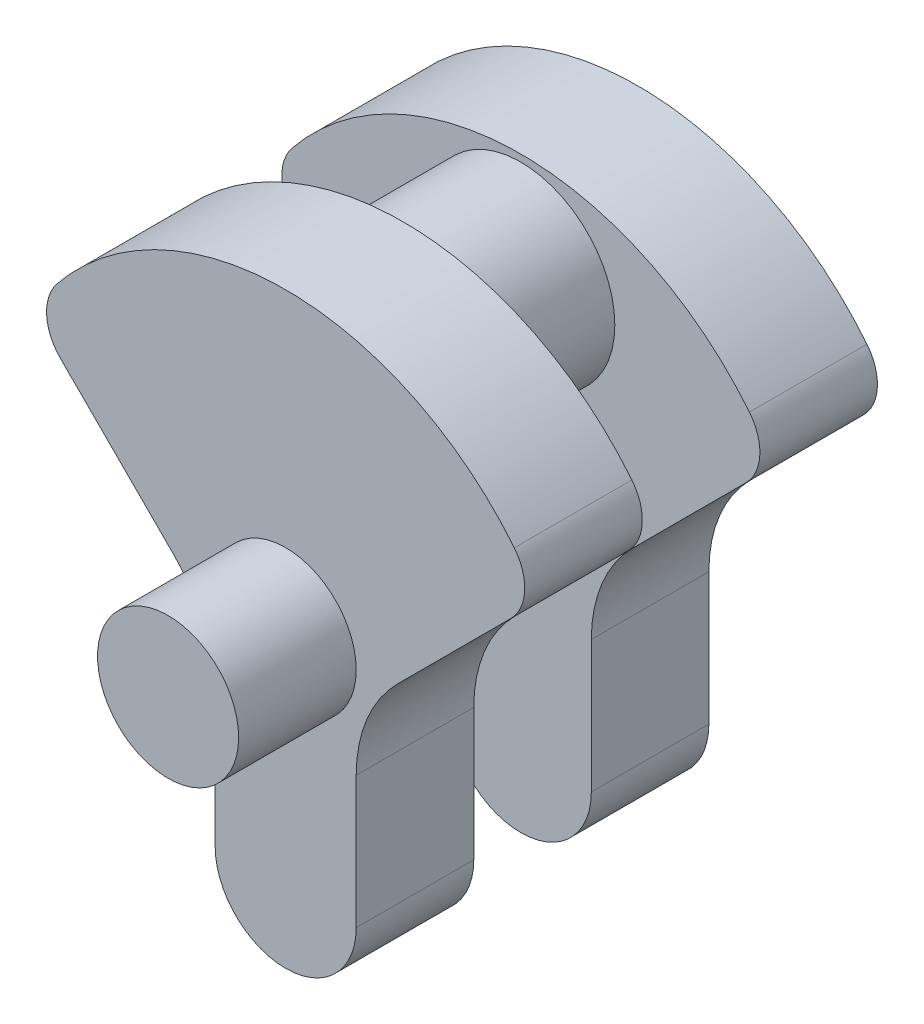
from build123d import *

# Parameters (mm, degrees)
BOSS_EXTRUDE1_DEPTH = 37.5
FILLET1_R           = 10
SKETCH4_W           = 25
SKETCH4_H           = 105.707635496
FILLET2_R           = 30
SKETCH5_R           = 15
BOSS_EXTRUDE2_DEPTH = 25


with BuildPart() as part:
    # Sketch2 → Boss-Extrude1 (new body, symmetric)
    with BuildSketch(Plane.XY):
        with BuildLine():
            Line((15, -47.5), (15, -7))
            Line((15, -7), (53.80332931, 31.80332931))
            ThreePointArc((53.80332931, 31.80332931), (0, 62.5), (-53.80332931, 31.80332931))
            Line((-53.80332931, 31.80332931), (-15, -7))
            Line((-15, -7), (-15, -47.5))
            ThreePointArc((-15, -47.5), (0, -62.5), (15, -47.5))
        make_face()
    extrude(amount=BOSS_EXTRUDE1_DEPTH, both=True)

    # Fillet1
    fillet1_edges = [part.edges().sort_by_distance(p)[0] for p in [
        (-53.80332931, 31.80332931, 0),
        (53.80332931, 31.80332931, 0),
    ]]
    fillet(fillet1_edges, radius=FILLET1_R)

    # Sketch4 → Cut-Revolve1 (revolve, cut)
    with BuildSketch(Plane(origin=(0, 0, 0), x_dir=(0, 0, -1), z_dir=(1, 0, 0)), mode=Mode.PRIVATE) as cut_revolve1_sk:
        with Locations((0, -31.853817748)):
            Rectangle(SKETCH4_W, SKETCH4_H)
    revolve(cut_revolve1_sk.sketch.rotate(Axis((0, 41, 37.5), (0, 0, -1)), 270), axis=Axis((0, 41, 37.5), (0, 0, -1)), mode=Mode.SUBTRACT)  # turned: the seam where the file's is

    # Fillet2
    fillet2_edges = [part.edges().sort_by_distance(p)[0] for p in [
        (15, -7, 25),
        (-15, -7, 25),
        (15, -7, -25),
        (-15, -7, -25),
    ]]
    fillet(fillet2_edges, radius=FILLET2_R)

    # Sketch5 → Boss-Extrude2 (add)
    with BuildSketch(Plane.XY.offset(37.5)):
        Circle(SKETCH5_R)
    boss_extrude2 = extrude(amount=BOSS_EXTRUDE2_DEPTH)

    # Mirror1: Boss-Extrude2 across plane
    add(boss_extrude2.mirror(Plane.XY))


solid = part.part
